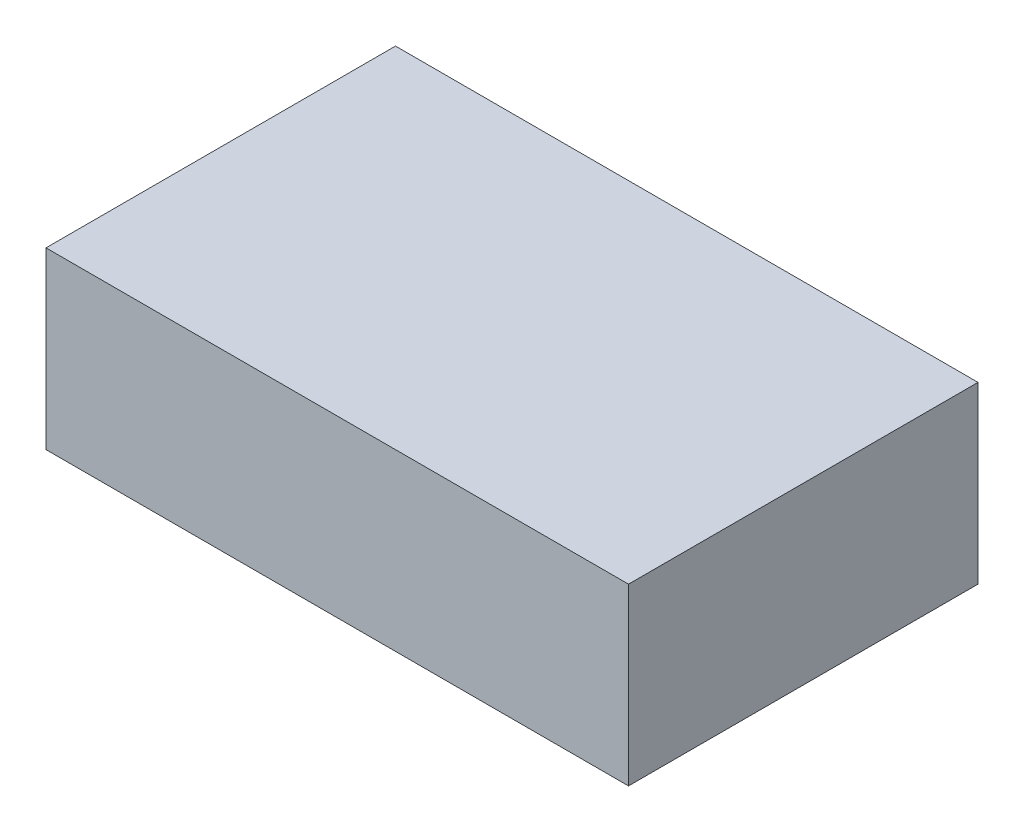
from build123d import *

# Parameters (mm, degrees)
SKETCH1_W           = 63.5
SKETCH1_H           = 38.1
BOSS_EXTRUDE1_DEPTH = 19.05


with BuildPart() as part:
    # Sketch1 → Boss-Extrude1 (new body)
    with BuildSketch(Plane(origin=(0, 0, 0), x_dir=(1, 0, 0), z_dir=(0, 1, 0))):
        with Locations((-31.75, 19.05)):
            Rectangle(SKETCH1_W, SKETCH1_H)
    extrude(amount=BOSS_EXTRUDE1_DEPTH)


solid = part.part
